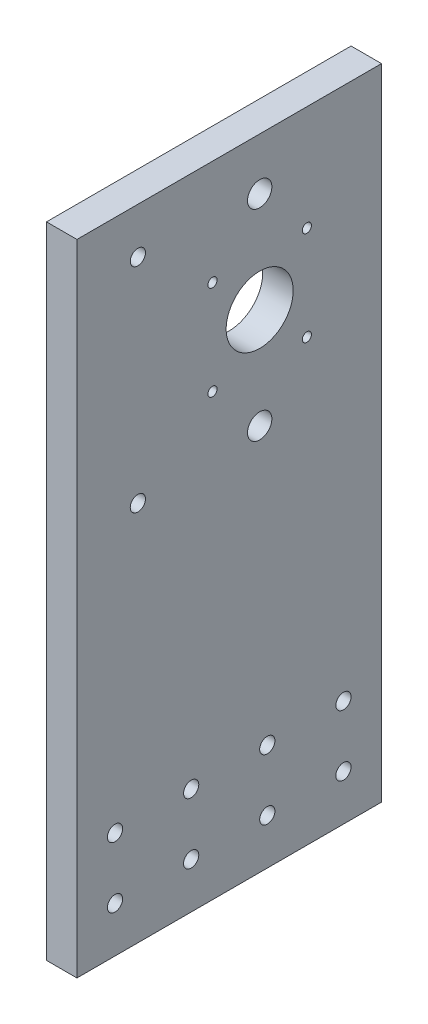
from build123d import *

# Parameters (mm, degrees)
SKETCH2_W                       = 100
SKETCH2_H                       = 210
SKETCH2_R                       = 4
BOSS_EXTRUDE1_DEPTH             = 10
SKETCH3_R                       = 2.5
MOUNT_DEPTH                     = 11
SKETCH7_R                       = 2.5
SUPPORT_PROFILE_MOUNT_DEPTH     = 11
SKETCH4_R                       = 11
SKETCH4_R_2                     = 1.5
STEPPER_MOUNT_DEPTH             = 11
SKETCH6_R                       = 2.75
STEPPER_MOUNT_COUNTERSINK_DEPTH = 3


with BuildPart() as part:
    # Sketch2 → Boss-Extrude1 (new body)
    with BuildSketch(Plane(origin=(0, 0, 0), x_dir=(0, 0, -1), z_dir=(1, 0, 0))):
        with Locations((-10, 0)):
            Rectangle(SKETCH2_W, SKETCH2_H)
        with Locations((0, 88)):
            Circle(SKETCH2_R, mode=Mode.SUBTRACT)
        with Locations((0, 22)):
            Circle(SKETCH2_R, mode=Mode.SUBTRACT)
    extrude(amount=BOSS_EXTRUDE1_DEPTH)

    # Sketch3 → mount (cut, through all)
    with BuildSketch(Plane(origin=(10, 0, 0), x_dir=(0, 0, -1), z_dir=(1, 0, 0))):
        with Locations((-22.5, -70)):
            Circle(SKETCH3_R)
        with Locations((-47.5, -70)):
            Circle(SKETCH3_R)
        with Locations((-47.5, -90)):
            Circle(SKETCH3_R)
        with Locations((-22.5, -90)):
            Circle(SKETCH3_R)
        with Locations((2.5, -90)):
            Circle(SKETCH3_R)
        with Locations((27.5, -90)):
            Circle(SKETCH3_R)
        with Locations((27.5, -70)):
            Circle(SKETCH3_R)
        with Locations((2.5, -70)):
            Circle(SKETCH3_R)
    extrude(amount=-MOUNT_DEPTH, mode=Mode.SUBTRACT)

    # Sketch7 → support_profile_mount (cut, through all)
    with BuildSketch(Plane(origin=(10, 0, 0), x_dir=(0, 0, -1), z_dir=(1, 0, 0))):
        with Locations((-40, 90)):
            Circle(SKETCH7_R)
        with Locations((-40, 20)):
            Circle(SKETCH7_R)
    extrude(amount=-SUPPORT_PROFILE_MOUNT_DEPTH, mode=Mode.SUBTRACT)

    # Sketch4 → stepper_mount (cut, through all)
    with BuildSketch(Plane(origin=(10, 0, 0), x_dir=(0, 0, -1), z_dir=(1, 0, 0))):
        with Locations((0, 55)):
            Circle(SKETCH4_R)
        with Locations((-15.5, 70.5)):
            Circle(SKETCH4_R_2)
        with Locations((15.5, 70.5)):
            Circle(SKETCH4_R_2)
        with Locations((-15.5, 39.5)):
            Circle(SKETCH4_R_2)
        with Locations((15.5, 39.5)):
            Circle(SKETCH4_R_2)
    extrude(amount=-STEPPER_MOUNT_DEPTH, mode=Mode.SUBTRACT)

    # Sketch6 → stepper_mount_countersink (cut)
    with BuildSketch(Plane.ZY):
        with Locations((-15.5, 70.5)):
            Circle(SKETCH6_R)
        with Locations((15.5, 70.5)):
            Circle(SKETCH6_R)
        with Locations((15.5, 39.5)):
            Circle(SKETCH6_R)
        with Locations((-15.5, 39.5)):
            Circle(SKETCH6_R)
    extrude(amount=-STEPPER_MOUNT_COUNTERSINK_DEPTH, mode=Mode.SUBTRACT)


solid = part.part
